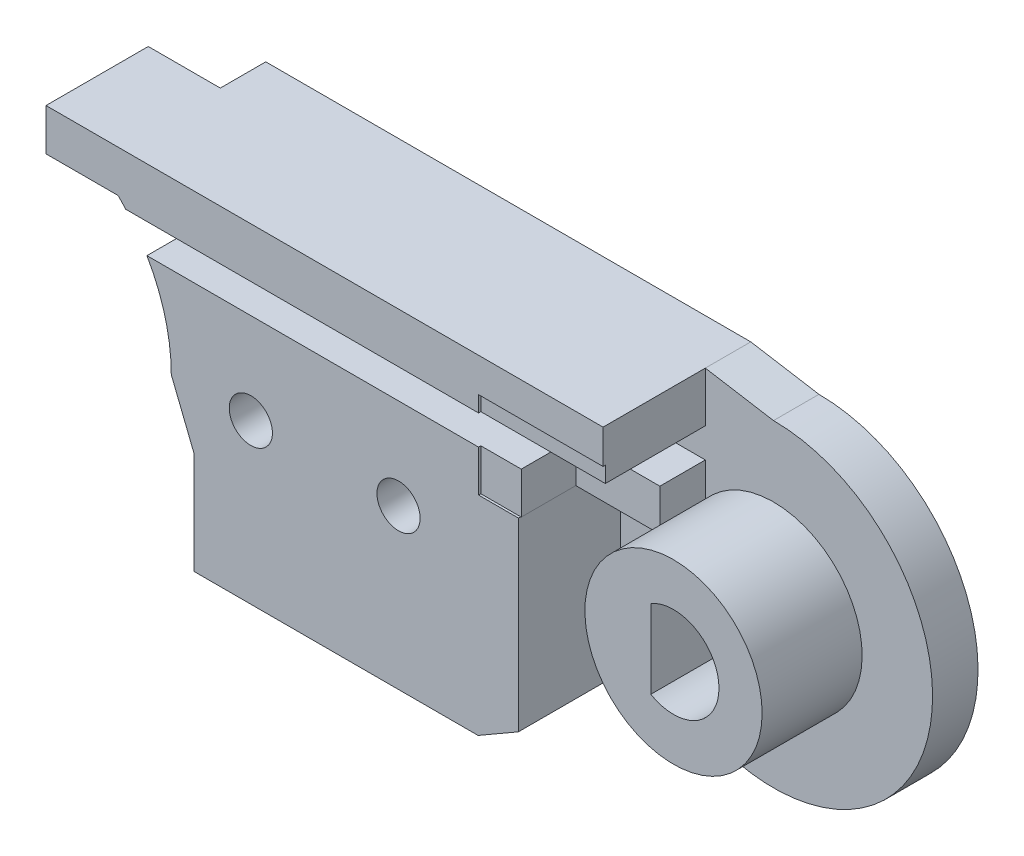
from build123d import *

# Parameters (mm, degrees)
BOSS_EXTRUDE1_DEPTH  = 2
BOSS_EXTRUDE6_DEPTH  = 4.5
CUT_EXTRUDE6_DEPTH   = 4.5
BOSS_EXTRUDE14_DEPTH = 2.3
SKETCH32_R           = 2.1
CUT_EXTRUDE7_DEPTH   = 2.3
SKETCH33_W           = 12.5
SKETCH33_H           = 1.343145751
BOSS_EXTRUDE15_DEPTH = 1.2
SKETCH35_W           = 5.479645997
SKETCH35_H           = 3.827993755
CUT_EXTRUDE8_DEPTH   = 2.4
SKETCH36_W           = 3.7
SKETCH36_H           = 1.827993755
CUT_EXTRUDE9_DEPTH   = 2.4
SKETCH37_R           = 3.9
BOSS_EXTRUDE16_DEPTH = 4.4
CUT_EXTRUDE10_DEPTH  = 7.4
SKETCH43_R           = 2.5
BOSS_EXTRUDE17_DEPTH = 1.2
SKETCH44_R           = 0.95
CUT_EXTRUDE11_DEPTH  = 11
SKETCH45_R           = 2
CUT_EXTRUDE12_DEPTH  = 4.5
SKETCH52_R           = 0.75
CUT_EXTRUDE13_DEPTH  = 10


with BuildPart() as part:
    # Sketch3 → Boss-Extrude1 (new body)
    with BuildSketch(Plane.XY):
        with BuildLine():
            Line((8, 0), (9, -2.5))
            Line((9, -2.5), (9, -7))
            Line((9, -7), (21.5, -7))
            Line((21.5, -7), (25.050252532, -4.949747468))
            ThreePointArc((25.050252532, -4.949747468), (36.467156728, -2.678784027), (30, 7))
            Line((30, 7), (27, 7.5))
            Line((27, 7.5), (5.656854249, 7.5))
            Line((5.656854249, 7.5), (5.656854249, 5.656854249))
            ThreePointArc((5.656854249, 5.656854249), (7.39103626, 3.061467459), (8, 0))
        make_face()
    extrude(amount=BOSS_EXTRUDE1_DEPTH)

    # Sketch22 → Boss-Extrude6 (add)
    with BuildSketch(Plane.XY.offset(2)):
        with BuildLine():
            Line((5.656854249, 5.656854249), (2.486790148, 5.656854249))
            Line((2.486790148, 5.656854249), (2.486790148, 7.5))
            Line((2.486790148, 7.5), (5.656854249, 7.5))
            Line((5.656854249, 7.5), (21.5, 7.5))
            Line((21.5, 7.5), (27, 7.5))
            Line((27, 7.5), (27, 2.172006245))
            Line((27, 2.172006245), (23.275126266, 2.172006245))
            Line((23.275126266, 2.172006245), (23.275126266, -5.974873734))
            Line((23.275126266, -5.974873734), (21.5, -7))
            Line((21.5, -7), (9, -7))
            Line((9, -7), (9, -2.5))
            Line((9, -2.5), (8, 0))
            ThreePointArc((8, 0), (7.39103626, 3.061467459), (5.656854249, 5.656854249))
        make_face()
    extrude(amount=BOSS_EXTRUDE6_DEPTH)

    # Sketch26 → Cut-Extrude6 (cut)
    with BuildSketch(Plane.XY.offset(2)):
        Polygon((18.098080448, 5.3), (2.530052458, 5.3), (2.530052458, 4), (18.098080448, 4), (27, 4), (27, 5.3), align=None)
    extrude(amount=CUT_EXTRUDE6_DEPTH, mode=Mode.SUBTRACT)


with BuildPart() as body_2:
    # Sketch31 → Boss-Extrude14 (new body)
    with BuildSketch(Plane.XY.offset(6.5)):
        with BuildLine():
            Line((2.432688066, 5.656854249), (0, 5.656854249))
            ThreePointArc((0, 5.656854249), (-5.656854249, 0), (0, -5.656854249))
            Line((0, -5.656854249), (9, -5.656854249))
            Line((9, -5.656854249), (9, -7))
            Line((9, -7), (21.5, -7))
            Line((21.5, -7), (23.275126266, -5.974873734))
            Line((23.275126266, -5.974873734), (23.275126266, 2.172006245))
            Line((23.275126266, 2.172006245), (27, 2.172006245))
            Line((27, 2.172006245), (27, 7.5))
            Line((27, 7.5), (2.486790148, 7.5))
            Line((2.486790148, 7.5), (2.432688066, 5.656854249))
        make_face()
    extrude(amount=BOSS_EXTRUDE14_DEPTH)

    # Sketch32 → Cut-Extrude7 (cut)
    with BuildSketch(Plane.XY.offset(8.8)):
        Circle(SKETCH32_R)
    extrude(amount=-CUT_EXTRUDE7_DEPTH, mode=Mode.SUBTRACT)

    # Sketch33 → Boss-Extrude15 (add)
    with BuildSketch(Plane.XY.offset(8.8)):
        with Locations((15.25, -6.328427125)):
            Rectangle(SKETCH33_W, SKETCH33_H)
        Polygon((2.486790148, 7.5), (21.5, 7.5), (21.5, 5.656854249), (2.432688066, 5.656854249), align=None)
    extrude(amount=BOSS_EXTRUDE15_DEPTH)


with BuildPart() as cut_extrude8_tool:
    # Sketch35 → Cut-Extrude8 (new body)
    with BuildSketch(Plane.XY.offset(8.8)):
        with Locations((24.260177002, 4.086003123)):
            Rectangle(SKETCH35_W, SKETCH35_H)
    extrude(amount=-CUT_EXTRUDE8_DEPTH)


with BuildPart() as part_1:
    add(part.part)

    # Cut-Extrude8: cut by cut_extrude8_tool
    add(cut_extrude8_tool.part, mode=Mode.SUBTRACT)

    # Sketch36 → Cut-Extrude9 (cut)
    with BuildSketch(Plane.XY.offset(6.4)):
        with Locations((25.15, 3.086003123)):
            Rectangle(SKETCH36_W, SKETCH36_H)
    extrude(amount=-CUT_EXTRUDE9_DEPTH, mode=Mode.SUBTRACT)

    # Sketch37 → Boss-Extrude16 (add)
    with BuildSketch(Plane.XY.offset(2)):
        with Locations((30, 0)):
            Circle(SKETCH37_R)
    extrude(amount=BOSS_EXTRUDE16_DEPTH)

    # Sketch39 → Cut-Extrude10 (cut, through all)
    with BuildSketch(Plane.XY.offset(6.4)):
        with BuildLine():
            Line((29, 1.732050808), (29, -1.732050808))
            ThreePointArc((29, -1.732050808), (32, 0), (29, 1.732050808))
        make_face()
    extrude(amount=-CUT_EXTRUDE10_DEPTH, mode=Mode.SUBTRACT)


with BuildPart() as body_2_1:
    add(body_2.part)

    # Cut-Extrude8: cut by cut_extrude8_tool
    add(cut_extrude8_tool.part, mode=Mode.SUBTRACT)

    # Sketch43 → Boss-Extrude17 (add)
    with BuildSketch(Plane.XY.offset(8.8)):
        with Locations((11.5, 0)):
            Circle(SKETCH43_R)
        with Locations((18, 0)):
            Circle(SKETCH43_R)
    extrude(amount=BOSS_EXTRUDE17_DEPTH)


with BuildPart() as cut_extrude11_tool:
    # Sketch44 → Cut-Extrude11 (new body, through all)
    with BuildSketch(Plane.XY.offset(10)):
        with Locations((11.5, 0)):
            Circle(SKETCH44_R)
        with Locations((18, 0)):
            Circle(SKETCH44_R)
    extrude(amount=-CUT_EXTRUDE11_DEPTH)


with BuildPart() as part_2:
    add(part_1.part)

    # Cut-Extrude11: cut by cut_extrude11_tool
    add(cut_extrude11_tool.part, mode=Mode.SUBTRACT)

    # Sketch45 → Cut-Extrude12 (cut)
    with BuildSketch(Plane(origin=(0, 0, 0), x_dir=(-1, 0, 0), z_dir=(0, 0, -1))):
        with Locations((-11.5, 0)):
            Circle(SKETCH45_R)
        with Locations((-18, 0)):
            Circle(SKETCH45_R)
    extrude(amount=-CUT_EXTRUDE12_DEPTH, mode=Mode.SUBTRACT)


with BuildPart() as body_2_2:
    add(body_2_1.part)

    # Cut-Extrude11: cut by cut_extrude11_tool
    add(cut_extrude11_tool.part, mode=Mode.SUBTRACT)

    # Sketch52 → Cut-Extrude13 (cut, along a direction that is not the sketch's normal)
    with BuildSketch(Plane.XZ.offset(-5.656854249)):
        with Locations((18.235476819, 10)):
            Circle(SKETCH52_R)
    extrude(amount=-CUT_EXTRUDE13_DEPTH, dir=(0.640410196, -0.76803306, 0), mode=Mode.SUBTRACT)


solid = part_2.part
